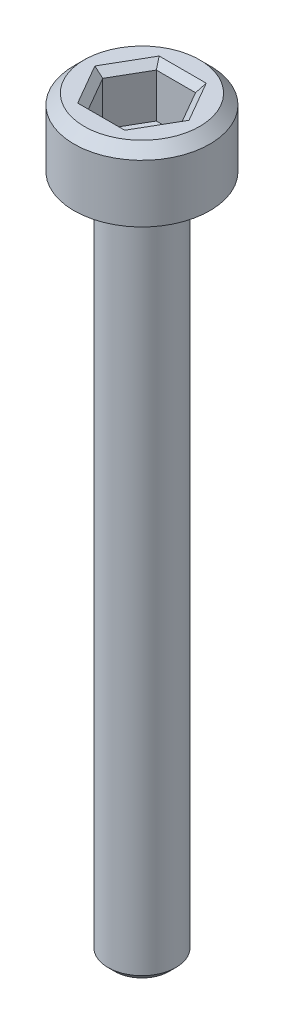
from build123d import *

# Parameters (mm, degrees)
SKETCH1_R           = 2
BOSS_EXTRUDE1_DEPTH = 2
CHAMFER1_SIZE       = 0.3
CUT_EXTRUDE1_DEPTH  = 1.5
CHAMFER2_SIZE       = 0.2
SKETCH3_R           = 1
BOSS_EXTRUDE2_DEPTH = 20
CHAMFER3_SIZE       = 0.2


with BuildPart() as part:
    # Sketch1 → Boss-Extrude1 (new body)
    with BuildSketch(Plane(origin=(0, 0, 0), x_dir=(1, 0, 0), z_dir=(0, 1, 0))):
        with Locations(Location((0, 0, 0), (0, 0, 270))):  # turned: the seam where the file's is
            Circle(SKETCH1_R)
    extrude(amount=BOSS_EXTRUDE1_DEPTH)

    # Chamfer1
    chamfer1_edges = [part.edges().sort_by_distance(p)[0] for p in [
        (0, 2, -2),
    ]]
    chamfer(chamfer1_edges, length=CHAMFER1_SIZE)

    # Sketch2 → Cut-Extrude1 (cut)
    with BuildSketch(Plane(origin=(0, 2, 0), x_dir=(1, 0, 0), z_dir=(0, 1, 0))):
        Polygon((1.154700538, 0), (0.577350269, 1), (-0.577350269, 1), (-1.154700538, 0), (-0.577350269, -1), (0.577350269, -1), align=None)
    extrude(amount=-CUT_EXTRUDE1_DEPTH, mode=Mode.SUBTRACT)

    # Chamfer2
    chamfer2_edges = [part.edges().sort_by_distance(p)[0] for p in [
        (0.866025404, 2, 0.5),
        (0.866025404, 2, -0.5),
        (0, 2, -1),
        (-0.866025404, 2, -0.5),
        (-0.866025404, 2, 0.5),
        (0, 2, 1),
    ]]
    chamfer(chamfer2_edges, length=CHAMFER2_SIZE)

    # Sketch3 → Boss-Extrude2 (add)
    with BuildSketch(Plane.XZ):
        with Locations(Location((0, 0, 0), (0, 0, 90))):  # turned: the seam where the file's is
            Circle(SKETCH3_R)
    extrude(amount=BOSS_EXTRUDE2_DEPTH)

    # Chamfer3
    chamfer3_edges = [part.edges().sort_by_distance(p)[0] for p in [
        (0, -20, -1),
    ]]
    chamfer(chamfer3_edges, length=CHAMFER3_SIZE)


solid = part.part
